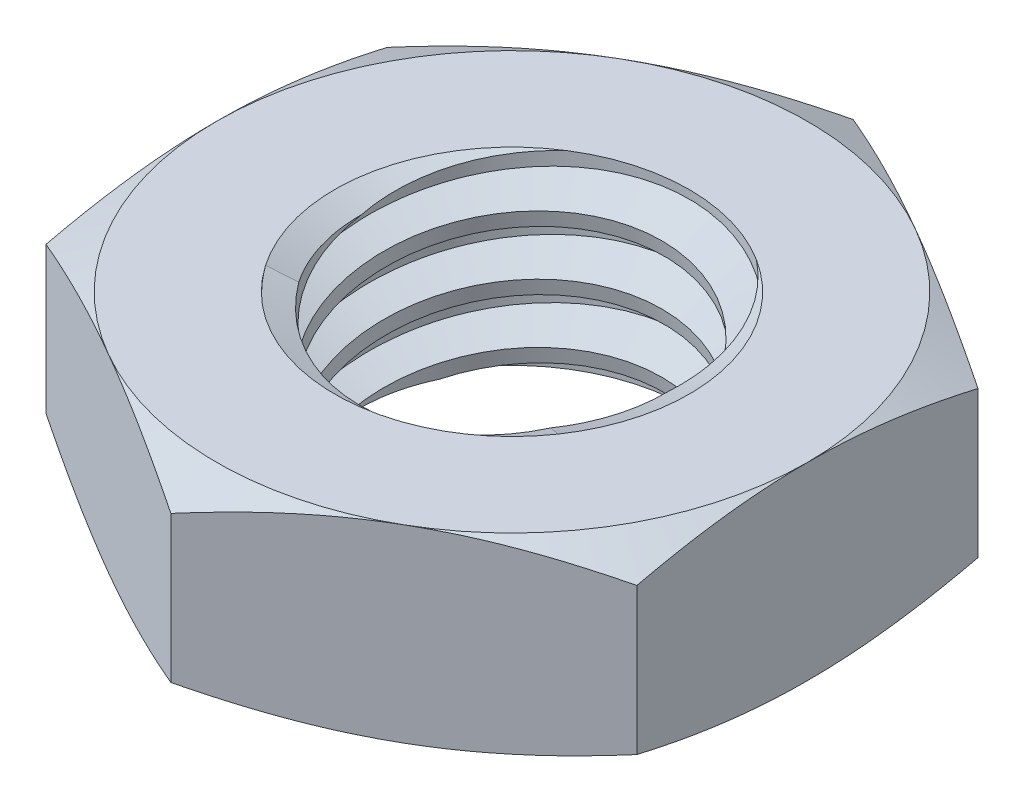
from build123d import *

# Parameters (mm, degrees)
EXTRUDE1_DEPTH      = 1.6
SKETCH2_W           = 3
SKETCH2_H           = 3.2
LPATTERN1_COUNT     = 3
LPATTERN1_PITCH     = 1
LPATTERN1_COL_COUNT = 2
LPATTERN1_COL_PITCH = 1


with BuildPart() as part:
    # Sketch1 → Extrude1 (new body, symmetric)
    with BuildSketch(Plane(origin=(0, 0, 0), x_dir=(1, 0, 0), z_dir=(0, 1, 0))):
        Polygon((0, 5.773502692), (-5, 2.886751346), (-5, -2.886751346), (0, -5.773502692), (5, -2.886751346), (5, 2.886751346), align=None)
    extrude(amount=EXTRUDE1_DEPTH, both=True)

    # Sketch4 → Cut-Revolve2 (revolve, cut)
    with BuildSketch(Plane(origin=(0, 0, 0), x_dir=(0, 0, -1), z_dir=(1, 0, 0))):
        Polygon((0, 1.6), (3, 1.6), (2.538023184, 1.384576673), (2.538023184, -1.384576673), (3, -1.6), (0, -1.6), align=None)
    revolve(axis=Axis((0, 1.6, 0), (0, 1, 0)), mode=Mode.SUBTRACT)


with BuildPart() as body_2:
    # Sketch2 → Revolve1 (revolve)
    with BuildSketch(Plane(origin=(0, 0, 0), x_dir=(0, 0, -1), z_dir=(1, 0, 0))):
        with Locations((1.5, 0)):
            Rectangle(SKETCH2_W, SKETCH2_H)
    revolve(axis=Axis((0, -4.6, 0), (0, 1, 0)))

    # Sketch3 → Cut-Revolve1 (revolve, cut)
    with BuildSketch(Plane(origin=(0, 0, 0), x_dir=(0, 0, -1), z_dir=(1, 0, 0))):
        Polygon((3.020549873, 1.47670076), (3.164398987, 0.613606076), (2.579122931, 0.832870615), (2.538023184, 1.079469096), align=None)
    cut_revolve1 = revolve(axis=Axis((0, 1.6, 0.178376498), (0, -0.986393924, -0.164398987)), mode=Mode.SUBTRACT)

    # LPattern1: Cut-Revolve1 ×3
    with Locations(*[(0, -i * LPATTERN1_PITCH, 0) for i in range(1, LPATTERN1_COUNT)]):
        add(cut_revolve1, mode=Mode.SUBTRACT)

    # LPattern1 col: Cut-Revolve1 ×2
    with Locations(*[(0, i * LPATTERN1_COL_PITCH, 0) for i in range(1, LPATTERN1_COL_COUNT)]):
        add(cut_revolve1, mode=Mode.SUBTRACT)


with BuildPart() as part_1:
    add(part.part)

    # Combine1: cut body 2
    add(body_2.part, mode=Mode.SUBTRACT)

    # Sketch5 → Cut-Revolve3 (revolve, cut)
    with BuildSketch(Plane(origin=(0, 0, 0), x_dir=(0, 0, -1), z_dir=(1, 0, 0))):
        Polygon((0, -1.6), (5, -1.6), (5.773502692, -1.239309771), (5.773502692, 1.239309771), (5, 1.6), (0, 1.6), (0, 2.87), (7.043502692, 2.87), (7.043502692, -2.87), (0, -2.87), align=None)
    revolve(axis=Axis((0, -1.6, 0), (0, 1, 0)), mode=Mode.SUBTRACT)


solid = part_1.part
